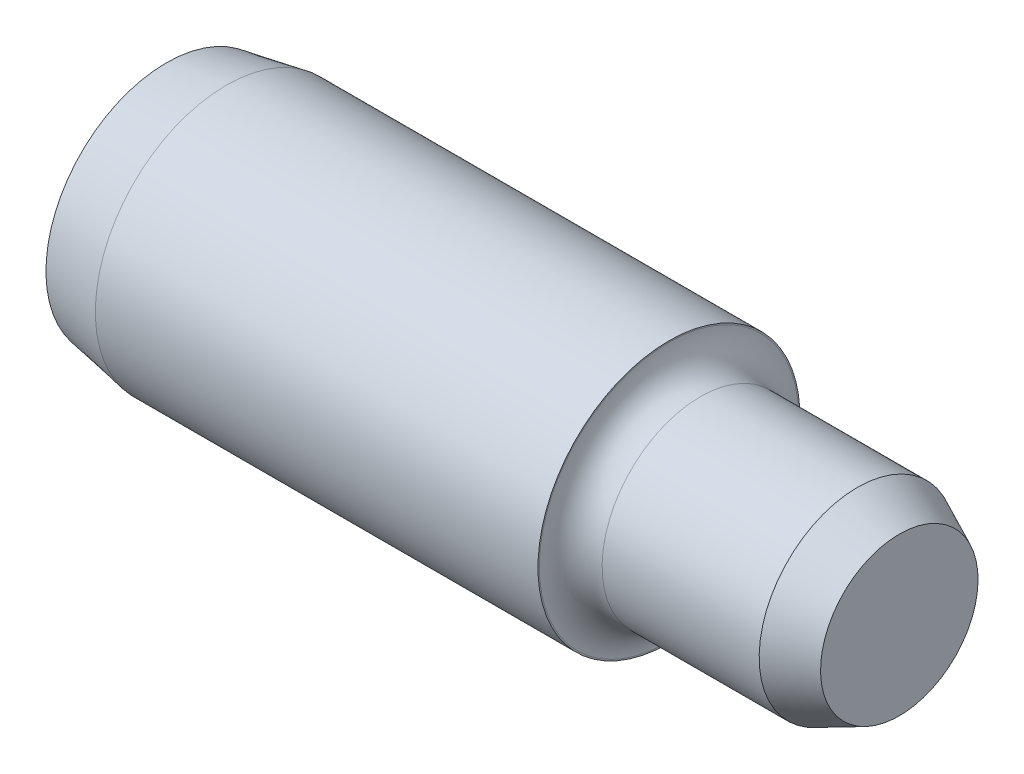
from build123d import *


with BuildPart() as part:
    # Sketch1 → Revolve1 (revolve)
    with BuildSketch(Plane.XY, mode=Mode.PRIVATE) as revolve1_sk:
        with BuildLine():
            Line((12.192, -3.17754), (12.192, -3.14579))
            ThreePointArc((12.192, -3.14579), (12.415184633, -2.606974633), (12.954, -2.38379))
            Line((12.954, -2.38379), (16.764, -2.38379))
            Line((16.764, -2.38379), (17.78, -1.910021419))
            Line((17.78, -1.910021419), (17.78, 0))
            Line((17.78, 0), (8.89, 0))
            Line((8.89, 0), (0, 0))
            Line((0, 0), (0, -2.921))
            Line((0, -2.921), (1.454910638, -3.17754))
            Line((1.454910638, -3.17754), (12.192, -3.17754))
        make_face()
    revolve(revolve1_sk.sketch.rotate(Axis((0, 0, 0), (-1, 0, 0)), 180), axis=Axis((0, 0, 0), (-1, 0, 0)))  # turned: the seam where the file's is


solid = part.part
